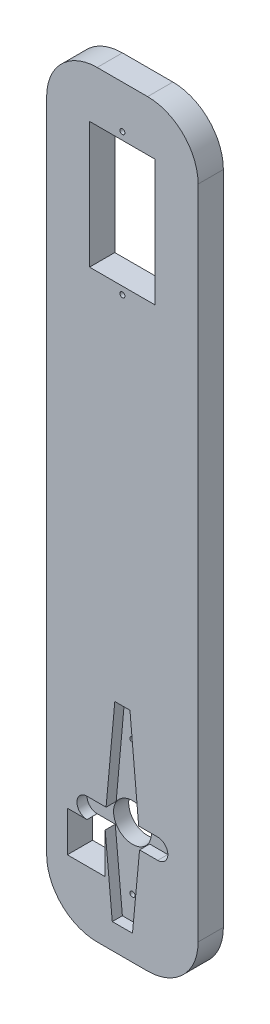
from build123d import *

# Parameters (mm, degrees)
SKICA1_W                 = 30
SKICA1_H                 = 150
P_IDAT_VYSUNUT_M1_DEPTH  = 5
ZAOBLIT1_R               = 10
SKICA2_W                 = 13
SKICA2_H                 = 25
ODEBRAT_VYSUNUT_M1_DEPTH = 6
SKICA3_R                 = 0.5
ODEBRAT_VYSUNUT_M2_DEPTH = 6
ODEBRAT_VYSUNUT_M3_DEPTH = 2
SKICA5_R                 = 0.5
ODEBRAT_VYSUNUT_M4_DEPTH = 4
SKICA6_R                 = 3.75
ODEBRAT_VYSUNUT_M5_DEPTH = 4
SKICA7_W                 = 7.5
SKICA7_H                 = 8
ODEBRAT_VYSUNUT_M6_DEPTH = 6


with BuildPart() as part:
    # Skica1 → Přidat vysunutím1 (new body)
    with BuildSketch(Plane.XY):
        with Locations((15, 75)):
            Rectangle(SKICA1_W, SKICA1_H)
    extrude(amount=P_IDAT_VYSUNUT_M1_DEPTH)

    # Zaoblit1
    zaoblit1_edges = [part.edges().sort_by_distance(p)[0] for p in [
        (0, 150, 2.5),
        (30, 150, 2.5),
        (30, 0, 2.5),
        (0, 0, 2.5),
    ]]
    fillet(zaoblit1_edges, radius=ZAOBLIT1_R)

    # Skica2 → Odebrat vysunutím1 (cut, through all)
    with BuildSketch(Plane.XY.offset(5)):
        with Locations((15, 127.5)):
            Rectangle(SKICA2_W, SKICA2_H)
    extrude(amount=-ODEBRAT_VYSUNUT_M1_DEPTH, mode=Mode.SUBTRACT)

    # Skica3 → Odebrat vysunutím2 (cut, through all)
    with BuildSketch(Plane.XY.offset(5)):
        with Locations((15, 141.5)):
            Circle(SKICA3_R)
        with Locations((15, 113.5)):
            Circle(SKICA3_R)
    extrude(amount=-ODEBRAT_VYSUNUT_M2_DEPTH, mode=Mode.SUBTRACT)

    # Skica4 → Odebrat vysunutím3 (cut)
    with BuildSketch(Plane.XY.offset(5)):
        Polygon((18.40625, 20), (11.59375, 20), (13, 5), (17, 5), align=None)
        Polygon((18.5, 21), (11.5, 21), (11.59375, 20), (18.40625, 20), align=None)
        Polygon((11.59375, 20), (11.5, 21), (11.772727273, 24), (8, 24), (8, 20), align=None)
        Polygon((11.772727273, 24), (11.5, 21), (18.5, 21), (18.227272727, 24), align=None)
        Polygon((18.227272727, 24), (18.5, 21), (18.40625, 20), (22, 20), (22, 24), align=None)
        with BuildLine():
            ThreePointArc((22, 24), (24, 22), (22, 20))
            Line((22, 20), (22, 24))
        make_face()
        with BuildLine():
            Line((8, 24), (8, 20))
            ThreePointArc((8, 20), (6, 22), (8, 24))
        make_face()
        Polygon((13.5, 43), (11.772727273, 24), (18.227272727, 24), (16.5, 43), align=None)
    extrude(amount=-ODEBRAT_VYSUNUT_M3_DEPTH, mode=Mode.SUBTRACT)

    # Skica5 → Odebrat vysunutím4 (cut, through all)
    with BuildSketch(Plane.XY.offset(3)):
        with Locations((15, 36.2)):
            Circle(SKICA5_R)
        with Locations((15, 9.7)):
            Circle(SKICA5_R)
    extrude(amount=-ODEBRAT_VYSUNUT_M4_DEPTH, mode=Mode.SUBTRACT)

    # Skica6 → Odebrat vysunutím5 (cut, through all)
    with BuildSketch(Plane.XY.offset(3)):
        with Locations((15, 22)):
            Circle(SKICA6_R)
    extrude(amount=-ODEBRAT_VYSUNUT_M5_DEPTH, mode=Mode.SUBTRACT)

    # Skica7 → Odebrat vysunutím6 (cut, through all)
    with BuildSketch(Plane.XY.offset(5)):
        with Locations((7.84375, 16)):
            Rectangle(SKICA7_W, SKICA7_H)
    extrude(amount=-ODEBRAT_VYSUNUT_M6_DEPTH, mode=Mode.SUBTRACT)


solid = part.part
